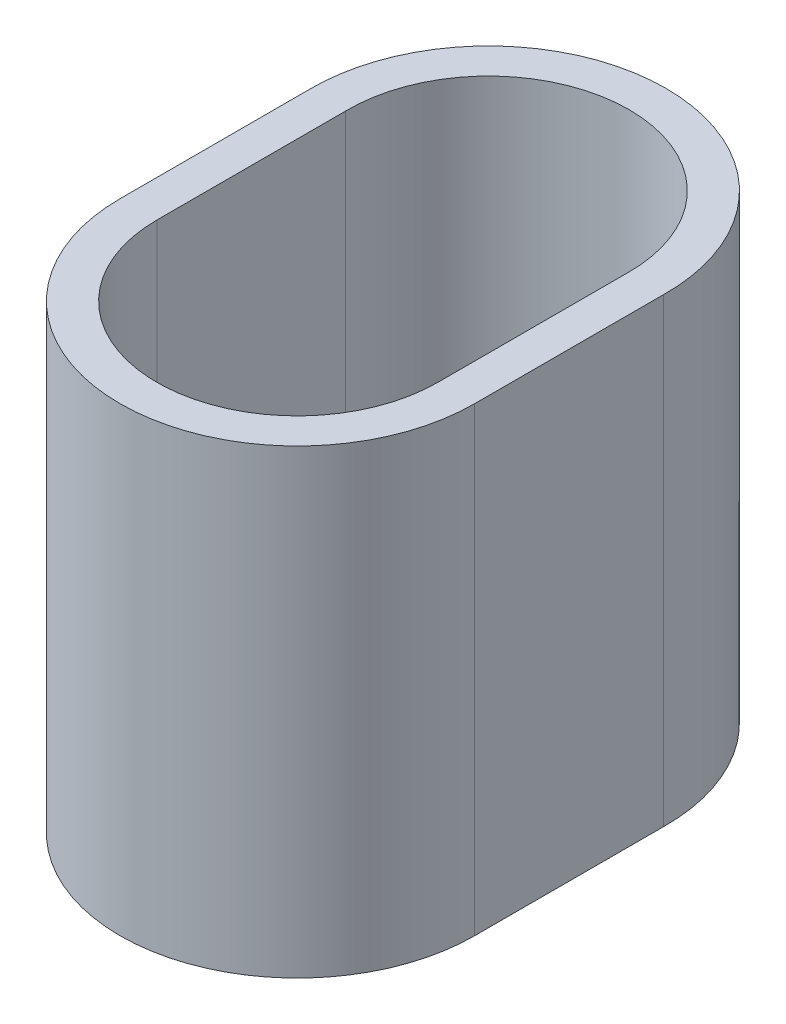
from build123d import *

# Parameters (mm, degrees)
BOSS_EXTRUDE2_DEPTH = 50


with BuildPart() as part:
    # Sketch1 → Boss-Extrude2 (new body)
    with BuildSketch(Plane(origin=(0, 0, 0), x_dir=(1, 0, 0), z_dir=(0, 1, 0))):
        with BuildLine():
            Line((-20.002173913, -10), (-20.002173913, 10.469122195))
            ThreePointArc((-20.002173913, 10.469122195), (-0.752173913, 30.002049043), (18.497826087, 10.469122195))
            Line((18.497826087, 10.469122195), (18.497826087, -10))
            ThreePointArc((18.497826087, -10), (-0.752173913, -29.25), (-20.002173913, -10))
        make_face()
        with BuildLine():
            Line((-16.002173913, -10), (-16.002173913, 10.5))
            ThreePointArc((-16.002173913, 10.5), (-0.752173913, 26.002049043), (14.497826087, 10.5))
            Line((14.497826087, 10.5), (14.497826087, -10))
            ThreePointArc((14.497826087, -10), (-0.752173913, -25.25), (-16.002173913, -10))
        make_face(mode=Mode.SUBTRACT)
    extrude(amount=BOSS_EXTRUDE2_DEPTH)


solid = part.part
